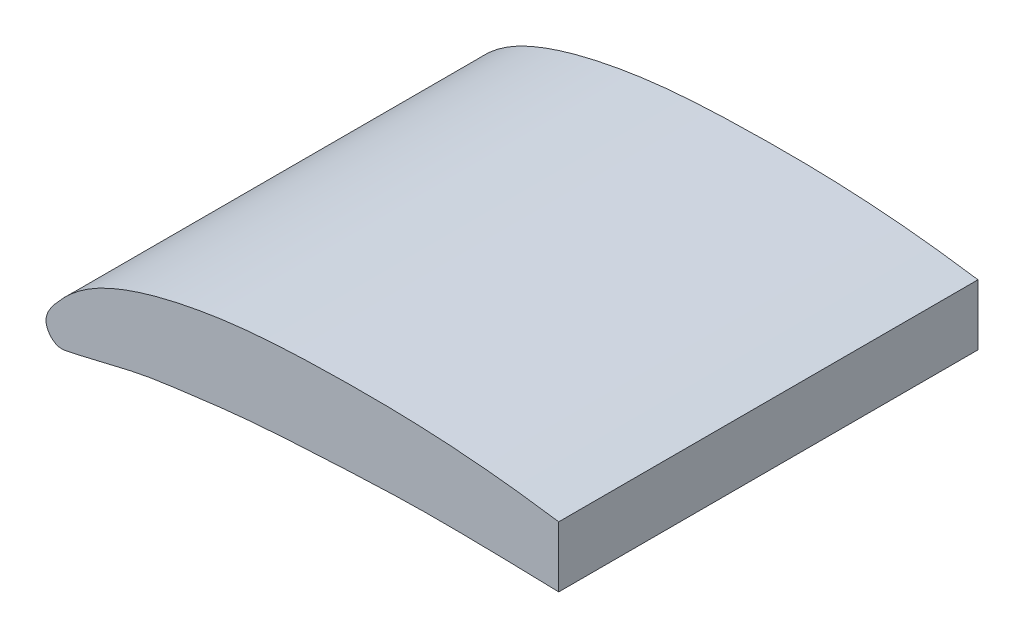
from build123d import *

# Parameters (mm, degrees)
BOSS_EXTRUDE1_DEPTH = 114.3


with BuildPart() as part:
    # Sketch1 → Boss-Extrude1 (new body)
    with BuildSketch(Plane.XY):
        with BuildLine():
            Line((139.7, 6.609889233), (139.7, 23.166170772))
            add(Edge.make_bspline(
                [(139.7, 23.166170772), (135.380629795, 23.805959403), (122.631010328, 25.528179282), (101.33320634, 27.152888319), (75.88557757, 27.17734948), (54.641071173, 26.194471962), (37.724116321, 23.47833263), (27.14178847, 20.862824139), (18.701701524, 17.836375149), (12.224566958, 14.719230964), (6.864342268, 10.853542834), (2.512358556, 6.225814587), (-1.732901636, 0.897528071), (2.557139286, -4.257017376), (7.562408352, -3.187950948), (12.698175589, -1.978811967), (19.049778871, -0.42591776), (27.433172343, 1.486520759), (38.05513002, 2.872460295), (54.924851174, 5.063535671), (76.118727982, 6.226952187), (101.511907224, 7.472150191), (122.714776143, 7.038119868), (135.441485908, 6.737356423), (139.7, 6.609889233)],
                knots=[0.223089178, 0.223089178, 0.223089178, 0.223089178, 0.248177787, 0.297011092, 0.345668692, 0.394384357, 0.418981925, 0.444018059, 0.456912726, 0.470404889, 0.485361367, 0.494028905, 0.508284262, 0.517561661, 0.523649238, 0.536104637, 0.548578769, 0.561002029, 0.585561942, 0.610032722, 0.658766283, 0.707434666, 0.756093744, 0.780575159, 0.780575159, 0.780575159, 0.780575159], degree=3))
        make_face()
    extrude(amount=BOSS_EXTRUDE1_DEPTH)


solid = part.part
